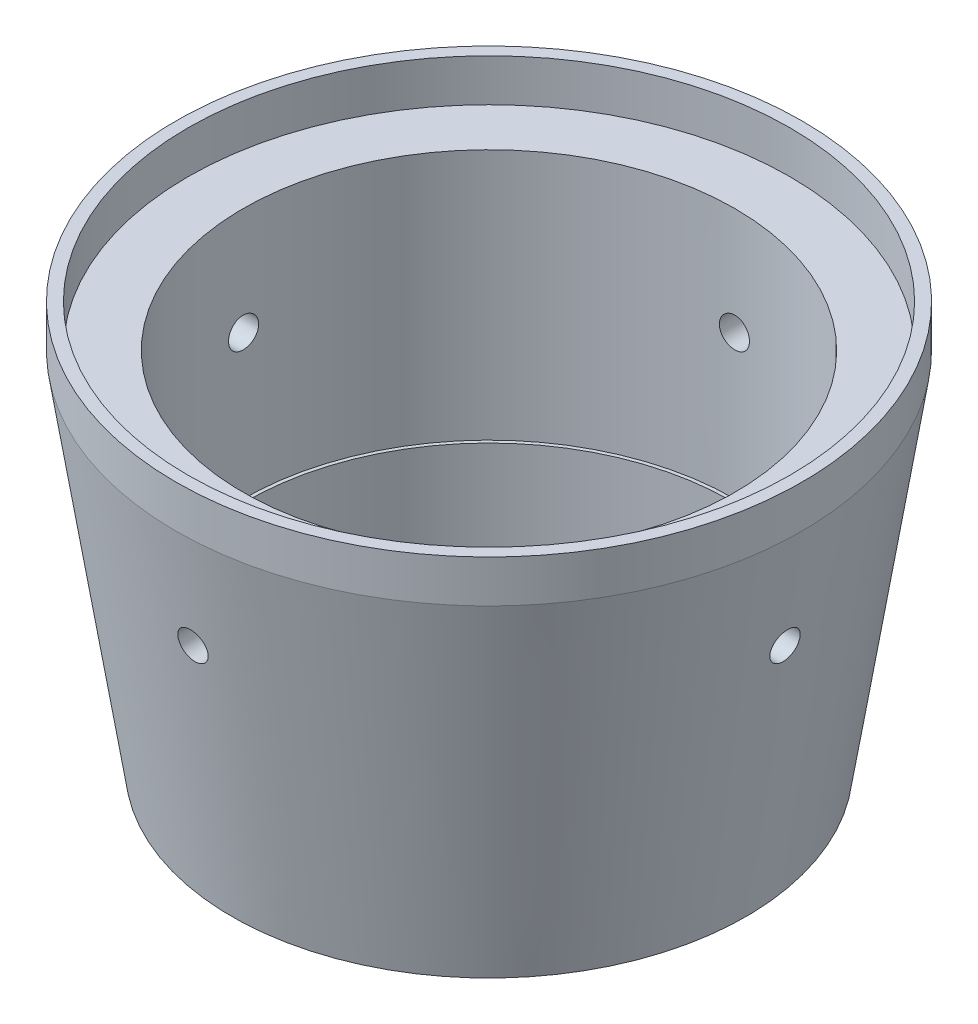
from build123d import *

# Parameters (mm, degrees)
F_6_32_TAPPED_HOLE1_REACH  = 74.635
F_6_32_TAPPED_HOLE1_BORE_R = 1.35255
CIRPATTERN2_COUNT          = 4
SKETCH6_R                  = 22.098
SKETCH6_R_2                = 21.7805
BOSS_EXTRUDE1_DEPTH        = 9.906


with BuildPart() as part:
    # Sketch1 → Revolve1 (revolve)
    with BuildSketch(Plane.XY, mode=Mode.PRIVATE) as revolve1_sk:
        Polygon((28.1305, 36.322), (28.1305, 32.512), (23.114, 0), (22.098, 0), (22.098, 32.512), (27.051, 32.512), (27.051, 36.322), align=None)
    revolve(revolve1_sk.sketch.rotate(Axis((0, -2.3241, 0), (0, 1, 0)), 90), axis=Axis((0, -2.3241, 0), (0, 1, 0)))

    # #6-32 Tapped Hole1 bore → #6-32 Tapped Hole1 (cut, up to next)
    with BuildSketch(Plane.XY.offset(28.1305), mode=Mode.PRIVATE) as f_6_32_tapped_hole1_sk1:
        with Locations((0, 22.86)):
            Circle(F_6_32_TAPPED_HOLE1_BORE_R)
    f_6_32_tapped_hole1_tool1 = extrude(f_6_32_tapped_hole1_sk1.sketch, amount=-F_6_32_TAPPED_HOLE1_REACH, mode=Mode.PRIVATE) & part.part
    f_6_32_tapped_hole1 = f_6_32_tapped_hole1_tool1.solids().sort_by_distance((0, 22.86, 28.1305))[0]
    add(f_6_32_tapped_hole1, mode=Mode.SUBTRACT)

    # CirPattern2: #6-32 Tapped Hole1 ×4 about axis
    cirpattern2_axis = Axis((0, 0, 0), (0, 1, 0))
    for i in range(1, CIRPATTERN2_COUNT):
        add(f_6_32_tapped_hole1.rotate(cirpattern2_axis, i * 360 / CIRPATTERN2_COUNT), mode=Mode.SUBTRACT)

    # Sketch6 → Boss-Extrude1 (add)
    with BuildSketch(Plane.XZ):
        with Locations(Location((0, 0, 0), (0, 0, 270))):
            Circle(SKETCH6_R)
        with Locations(Location((0, 0, 0), (0, 0, 270))):
            Circle(SKETCH6_R_2, mode=Mode.SUBTRACT)
    extrude(amount=-BOSS_EXTRUDE1_DEPTH)


solid = part.part
